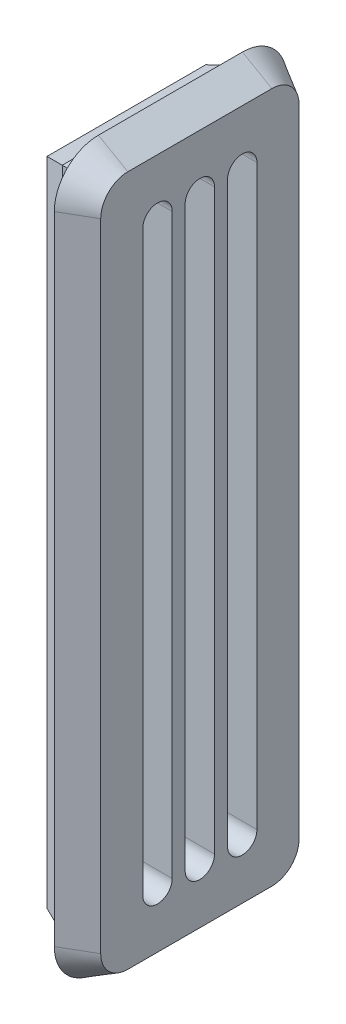
from build123d import *

# Parameters (mm, degrees)
SKETCH_1_W          = 11.8
SKETCH_1_H          = 45.3
SKETCH_1_W_2        = 8.8
SKETCH_1_H_2        = 42.3
EXTRUDE_1_DEPTH     = 3
EXTRUDE_2_DEPTH     = 2
EXTRUDE_2_TAPER     = 30
CUT_EXTRUDE_1_REACH = 4
CHAMFER_1_SIZE      = 0.5
CHAMFER_1_SIZE2     = 1.538841769


with BuildPart() as part:
    # 草图1 → 凸台-拉伸1 (new body)
    with BuildSketch(Plane(origin=(0, 0, 0), x_dir=(0, 0, -1), z_dir=(1, 0, 0))):
        with Locations((-141.359181517, 44.911156128)):
            Rectangle(SKETCH_1_W, SKETCH_1_H)
        with Locations((-141.359181517, 44.911156128)):
            Rectangle(SKETCH_1_W_2, SKETCH_1_H_2, mode=Mode.SUBTRACT)
    extrude(amount=EXTRUDE_1_DEPTH)

    # 草图2 → 凸台-拉伸2 (add)
    with BuildSketch(Plane(origin=(3, 0, 0), x_dir=(0, 0, -1), z_dir=(1, 0, 0))):
        with BuildLine():
            Line((-146.259181517, 20.261156128), (-136.459181517, 20.261156128))
            ThreePointArc((-136.459181517, 20.261156128), (-134.337861173, 21.139835784), (-133.459181517, 23.261156128))
            Line((-133.459181517, 23.261156128), (-133.459181517, 66.561156128))
            ThreePointArc((-133.459181517, 66.561156128), (-134.337861173, 68.682476471), (-136.459181517, 69.561156128))
            Line((-136.459181517, 69.561156128), (-146.259181517, 69.561156128))
            ThreePointArc((-146.259181517, 69.561156128), (-148.38050186, 68.682476471), (-149.259181517, 66.561156128))
            Line((-149.259181517, 66.561156128), (-149.259181517, 23.261156128))
            ThreePointArc((-149.259181517, 23.261156128), (-148.38050186, 21.139835784), (-146.259181517, 20.261156128))
        make_face()
    extrude(amount=EXTRUDE_2_DEPTH, taper=EXTRUDE_2_TAPER)

    # 草图3 → 切除-拉伸1 (cut, up to next)
    with BuildSketch(Plane.ZY.offset(-3), mode=Mode.PRIVATE) as cut_extrude_1_sk1:
        with BuildLine():
            Line((145.241468338, 64.561156128), (145.241468338, 25.261156128))
            ThreePointArc((145.241468338, 25.261156128), (144.241468338, 24.261156128), (143.241468338, 25.261156128))
            Line((143.241468338, 25.261156128), (143.241468338, 64.561156128))
            ThreePointArc((143.241468338, 64.561156128), (144.241468338, 65.561156128), (145.241468338, 64.561156128))
        make_face()
    cut_extrude_1_tool1 = extrude(cut_extrude_1_sk1.sketch, amount=-CUT_EXTRUDE_1_REACH, mode=Mode.PRIVATE) & part.part
    add(cut_extrude_1_tool1.solids().sort_by_distance((3, 44.911156, 144.241468))[0], mode=Mode.SUBTRACT)
    # 草图3 → 切除-拉伸1 (cut, up to next)
    with BuildSketch(Plane.ZY.offset(-3), mode=Mode.PRIVATE) as cut_extrude_1_sk2:
        with BuildLine():
            Line((142.359181517, 64.561156128), (142.359181517, 25.261156128))
            ThreePointArc((142.359181517, 25.261156128), (141.359181517, 24.261156128), (140.359181517, 25.261156128))
            Line((140.359181517, 25.261156128), (140.359181517, 64.561156128))
            ThreePointArc((140.359181517, 64.561156128), (141.359181517, 65.561156128), (142.359181517, 64.561156128))
        make_face()
    cut_extrude_1_tool2 = extrude(cut_extrude_1_sk2.sketch, amount=-CUT_EXTRUDE_1_REACH, mode=Mode.PRIVATE) & part.part
    add(cut_extrude_1_tool2.solids().sort_by_distance((3, 44.911156, 141.359182))[0], mode=Mode.SUBTRACT)
    # 草图3 → 切除-拉伸1 (cut, up to next)
    with BuildSketch(Plane.ZY.offset(-3), mode=Mode.PRIVATE) as cut_extrude_1_sk3:
        with BuildLine():
            Line((139.476894696, 64.561156128), (139.476894696, 25.261156128))
            ThreePointArc((139.476894696, 25.261156128), (138.476894696, 24.261156128), (137.476894696, 25.261156128))
            Line((137.476894696, 25.261156128), (137.476894696, 64.561156128))
            ThreePointArc((137.476894696, 64.561156128), (138.476894696, 65.561156128), (139.476894696, 64.561156128))
        make_face()
    cut_extrude_1_tool3 = extrude(cut_extrude_1_sk3.sketch, amount=-CUT_EXTRUDE_1_REACH, mode=Mode.PRIVATE) & part.part
    add(cut_extrude_1_tool3.solids().sort_by_distance((3, 44.911156, 138.476895))[0], mode=Mode.SUBTRACT)

    # 倒角1
    chamfer_1_edges = [part.edges().sort_by_distance(p)[0] for p in [
        (0, 67.561156128, 141.359181517),
        (0, 44.911156128, 135.459181517),
        (0, 22.261156128, 141.359181517),
        (0, 44.911156128, 147.259181517),
    ]]
    chamfer_1_side = [part.faces().sort_by_distance(p)[0] for p in [
        (0, 67.093039689, 141.359181517),
    ]]
    chamfer(chamfer_1_edges, length=CHAMFER_1_SIZE, length2=CHAMFER_1_SIZE2, reference=chamfer_1_side[0])


solid = part.part
